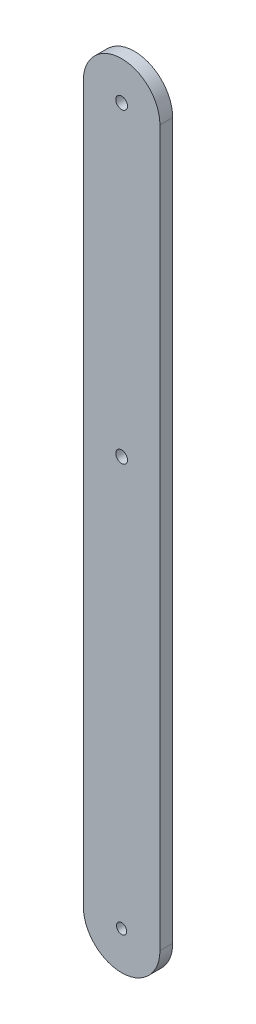
from build123d import *

# Parameters (mm, degrees)
SKETCH1_R           = 1.27
SKETCH1_R_2         = 1.4605
BOSS_EXTRUDE1_DEPTH = 3.175


with BuildPart() as part:
    # Sketch1 → Boss-Extrude1 (new body)
    with BuildSketch(Plane.XY):
        with BuildLine():
            Line((-19.353012887, -25.4), (-19.353012887, 152.4))
            ThreePointArc((-19.353012887, 152.4), (-9.828012887, 161.925), (-0.303012887, 152.4))
            Line((-0.303012887, 152.4), (-0.303012887, -25.4))
            ThreePointArc((-0.303012887, -25.4), (-9.828012887, -34.925), (-19.353012887, -25.4))
        make_face()
        with Locations((-9.828012887, -25.4)):
            Circle(SKETCH1_R, mode=Mode.SUBTRACT)
        with Locations((-9.828012887, 152.4)):
            Circle(SKETCH1_R_2, mode=Mode.SUBTRACT)
        with Locations((-9.828012887, 76.2)):
            Circle(SKETCH1_R_2, mode=Mode.SUBTRACT)
    extrude(amount=BOSS_EXTRUDE1_DEPTH)


solid = part.part
